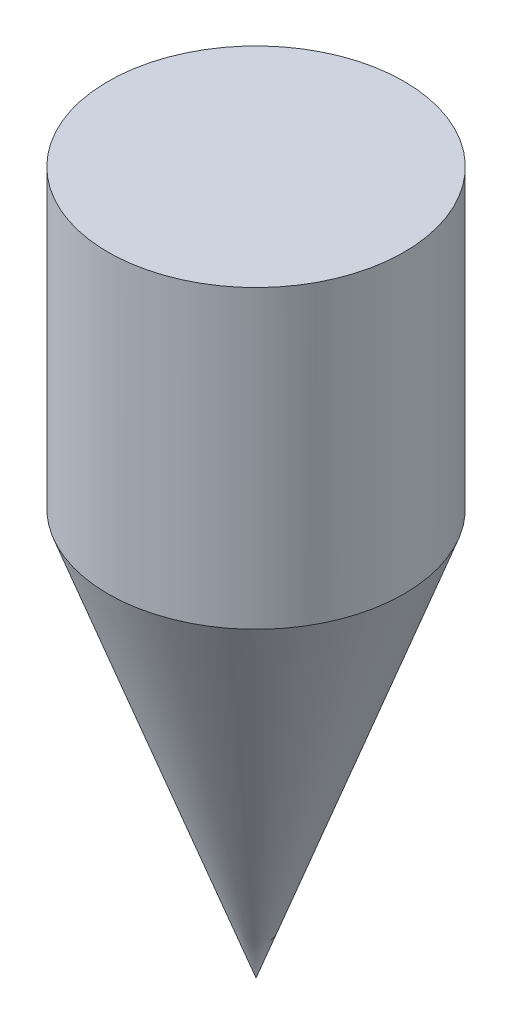
from build123d import *


with BuildPart() as part:
    # Sketch1 → Revolve1 (revolve)
    with BuildSketch(Plane.XY, mode=Mode.PRIVATE) as revolve1_sk:
        Polygon((-5, 37.183691589), (-5, 27.183691589), (0, 13.446304491), (0, 37.183691589), align=None)
    revolve(revolve1_sk.sketch.rotate(Axis((0, 0, 0), (0, 1, 0)), 270), axis=Axis((0, 0, 0), (0, 1, 0)))  # turned: the seam where the file's is


solid = part.part
